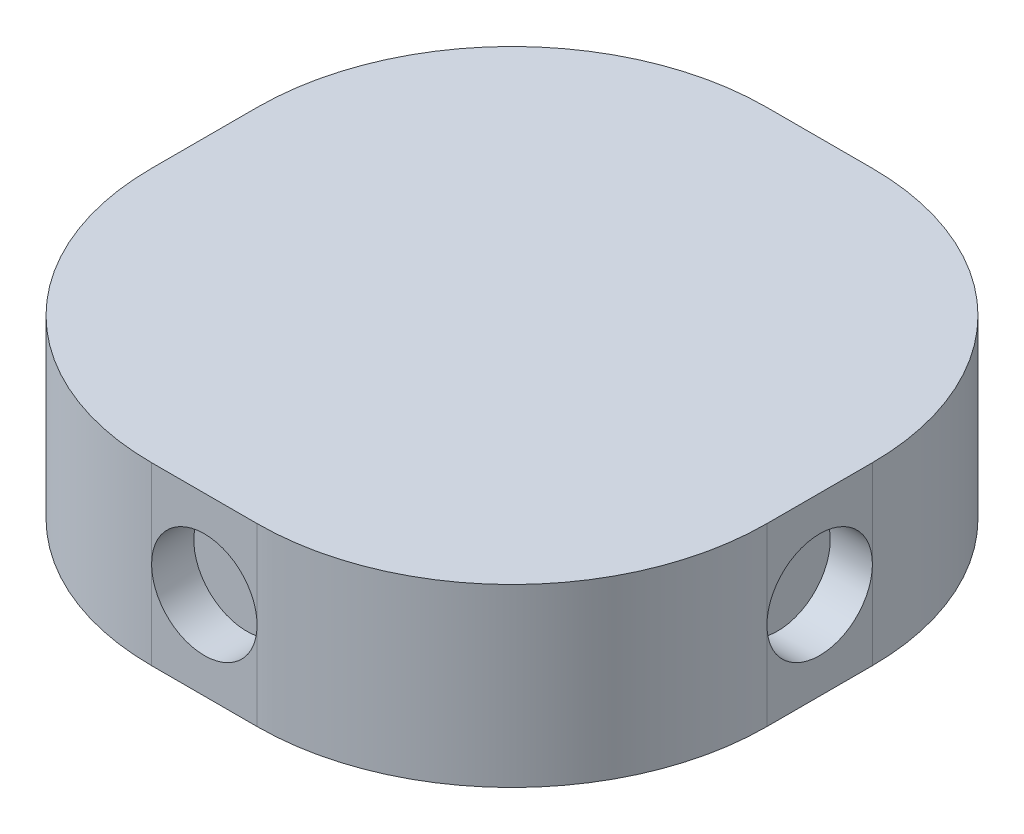
from build123d import *

# Parameters (mm, degrees)
BOSS_EXTRUDE3_DEPTH = 5
SKETCH3_R           = 1.5
CUT_EXTRUDE1_DEPTH  = 1.2
SKETCH4_R           = 1.5
CUT_EXTRUDE2_DEPTH  = 1.2
SKETCH5_R           = 1.5
CUT_EXTRUDE3_DEPTH  = 1.2
SKETCH6_R           = 1.5
CUT_EXTRUDE4_DEPTH  = 1.2


with BuildPart() as part:
    # Sketch1 → Boss-Extrude3 (new body)
    with BuildSketch(Plane(origin=(0, 0, 0), x_dir=(1, 0, 0), z_dir=(0, 1, 0))):
        with BuildLine():
            Line((-128.067602034, -163.739757522), (-125.067602034, -163.739757522))
            ThreePointArc((-125.067602034, -163.739757522), (-119.94107787, -161.616281686), (-117.817602034, -156.489757522))
            Line((-117.817602034, -156.489757522), (-117.817602034, -153.489757522))
            ThreePointArc((-117.817602034, -153.489757522), (-119.94107787, -148.363233359), (-125.067602034, -146.239757522))
            Line((-125.067602034, -146.239757522), (-128.067602034, -146.239757522))
            ThreePointArc((-128.067602034, -146.239757522), (-133.194126197, -148.363233359), (-135.317602034, -153.489757522))
            Line((-135.317602034, -153.489757522), (-135.317602034, -156.489757522))
            ThreePointArc((-135.317602034, -156.489757522), (-133.194126197, -161.616281686), (-128.067602034, -163.739757522))
        make_face()
    extrude(amount=BOSS_EXTRUDE3_DEPTH)

    # Sketch3 → Cut-Extrude1 (cut)
    with BuildSketch(Plane(origin=(0, 0, 146.239757522), x_dir=(-1, 0, 0), z_dir=(0, 0, -1))):
        with Locations((126.567602034, 2.5)):
            Circle(SKETCH3_R)
    extrude(amount=-CUT_EXTRUDE1_DEPTH, mode=Mode.SUBTRACT)

    # Sketch4 → Cut-Extrude2 (cut)
    with BuildSketch(Plane(origin=(-117.817602034, 0, 0), x_dir=(0, 0, -1), z_dir=(1, 0, 0))):
        with Locations((-154.989757522, 2.5)):
            Circle(SKETCH4_R)
    extrude(amount=-CUT_EXTRUDE2_DEPTH, mode=Mode.SUBTRACT)

    # Sketch5 → Cut-Extrude3 (cut)
    with BuildSketch(Plane.ZY.offset(135.317602034)):
        with Locations((154.989757522, 2.5)):
            Circle(SKETCH5_R)
    extrude(amount=-CUT_EXTRUDE3_DEPTH, mode=Mode.SUBTRACT)

    # Sketch6 → Cut-Extrude4 (cut)
    with BuildSketch(Plane.XY.offset(163.739757522)):
        with Locations((-126.567602034, 2.5)):
            Circle(SKETCH6_R)
    extrude(amount=-CUT_EXTRUDE4_DEPTH, mode=Mode.SUBTRACT)


solid = part.part
